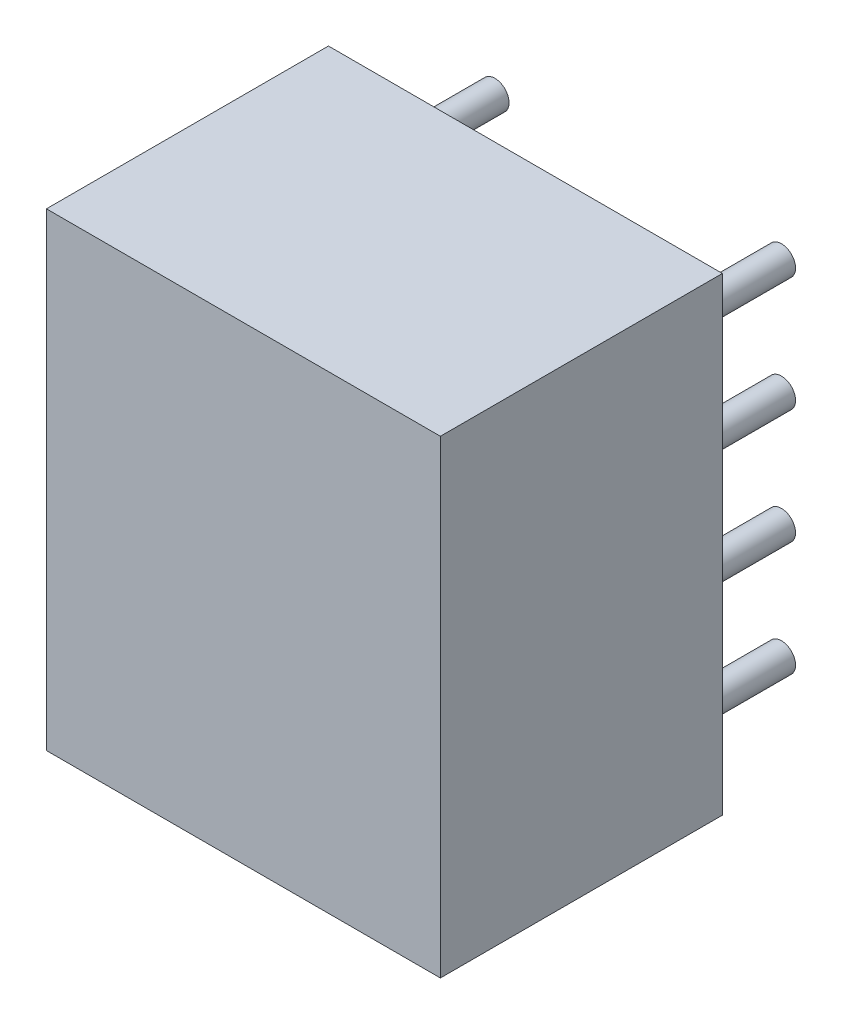
from build123d import *

# Parameters (mm, degrees)
SKETCH1_W               = 6.985
SKETCH1_H               = 8.3185
COMPONENT_OUTLINE_DEPTH = 5
SKETCH2_R               = 0.25
EXTRUDE_1_DEPTH         = 2
SKETCH3_R               = 0.25
BOSS_EXTRUDE3_DEPTH     = 2
SKETCH4_R               = 0.25
BOSS_EXTRUDE4_DEPTH     = 2
SKETCH5_R               = 0.25
BOSS_EXTRUDE5_DEPTH     = 2
SKETCH6_R               = 0.25
EXTRUDE_2_DEPTH         = 2
SKETCH7_R               = 0.25
EXTRUDE_3_DEPTH         = 2
SKETCH8_R               = 0.25
EXTRUDE_4_DEPTH         = 2
SKETCH9_R               = 0.25
EXTRUDE_5_DEPTH         = 2


with BuildPart() as part:
    # Sketch1 → Component_Outline (new body)
    with BuildSketch(Plane.XY):
        with Locations((2.54, 3.20675)):
            Rectangle(SKETCH1_W, SKETCH1_H)
    extrude(amount=COMPONENT_OUTLINE_DEPTH)


with BuildPart() as body_2:
    # Sketch2 → Extrude 1 (new body)
    with BuildSketch(Plane.XY):
        with Locations((5.08, 0)):
            Circle(SKETCH2_R)
    extrude(amount=-EXTRUDE_1_DEPTH)


with BuildPart() as body_3:
    # Sketch3 → Boss-Extrude3 (new body)
    with BuildSketch(Plane.XY):
        with Locations((5.08, 2.032)):
            Circle(SKETCH3_R)
    extrude(amount=-BOSS_EXTRUDE3_DEPTH)


with BuildPart() as body_4:
    # Sketch4 → Boss-Extrude4 (new body)
    with BuildSketch(Plane.XY):
        with Locations((5.08, 4.064)):
            Circle(SKETCH4_R)
    extrude(amount=-BOSS_EXTRUDE4_DEPTH)


with BuildPart() as body_5:
    # Sketch5 → Boss-Extrude5 (new body)
    with BuildSketch(Plane.XY):
        with Locations((5.08, 6.096)):
            Circle(SKETCH5_R)
    extrude(amount=-BOSS_EXTRUDE5_DEPTH)


with BuildPart() as body_6:
    # Sketch6 → Extrude 2 (new body)
    with BuildSketch(Plane.XY):
        Circle(SKETCH6_R)
    extrude(amount=-EXTRUDE_2_DEPTH)


with BuildPart() as body_7:
    # Sketch7 → Extrude 3 (new body)
    with BuildSketch(Plane.XY):
        with Locations((0, 2.032)):
            Circle(SKETCH7_R)
    extrude(amount=-EXTRUDE_3_DEPTH)


with BuildPart() as body_8:
    # Sketch8 → Extrude 4 (new body)
    with BuildSketch(Plane.XY):
        with Locations((0, 4.064)):
            Circle(SKETCH8_R)
    extrude(amount=-EXTRUDE_4_DEPTH)


with BuildPart() as body_9:
    # Sketch9 → Extrude 5 (new body)
    with BuildSketch(Plane.XY):
        with Locations((0, 6.096)):
            Circle(SKETCH9_R)
    extrude(amount=-EXTRUDE_5_DEPTH)


solid = Compound([part.part, body_2.part, body_3.part, body_4.part, body_5.part, body_6.part, body_7.part, body_8.part, body_9.part])
